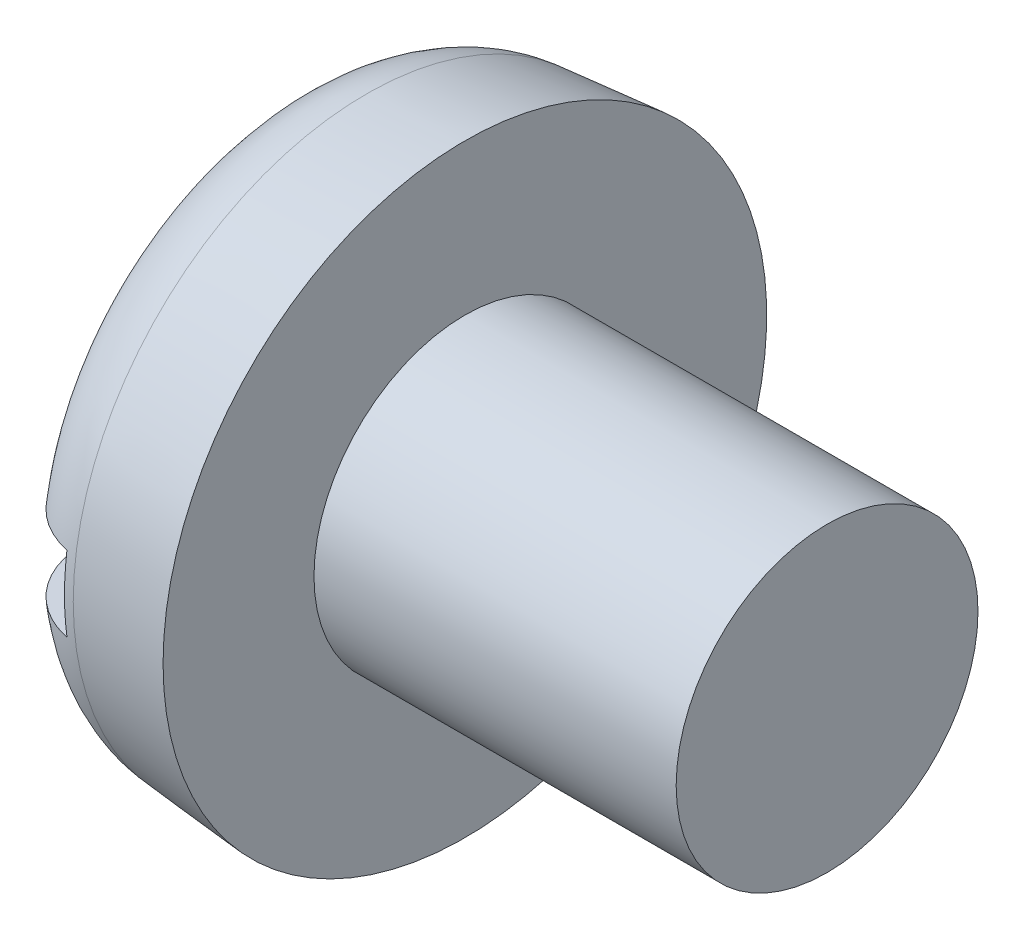
from build123d import *

# Parameters (mm, degrees)
FILLET2_R  = 3
SKETCH2_W  = 20
SKETCH2_H  = 2.5
SLOT_DEPTH = 2.4


with BuildPart() as part:
    # BodySke → Base-Revolve (revolve)
    with BuildSketch(Plane.XY, mode=Mode.PRIVATE) as base_revolve_sk:
        Polygon((6, 5), (6, 10), (0, 9.475068019), (0, 0), (18, 0), (18, 5), align=None)
    revolve(base_revolve_sk.sketch.rotate(Axis((-25.4, 0, 0), (1, 0, 0)), 90), axis=Axis((-25.4, 0, 0), (1, 0, 0)))  # turned: the seam where the file's is

    # Fillet2
    fillet2_edges = [part.edges().sort_by_distance(p)[0] for p in [
        (0, 0, -9.475068019),
    ]]
    fillet(fillet2_edges, radius=FILLET2_R)

    # Sketch2 → Slot (cut)
    with BuildSketch(Plane(origin=(0, 0, 0), x_dir=(0, 0, -1), z_dir=(1, 0, 0))):
        Rectangle(SKETCH2_W, SKETCH2_H)
    extrude(amount=SLOT_DEPTH, mode=Mode.SUBTRACT)


solid = part.part
